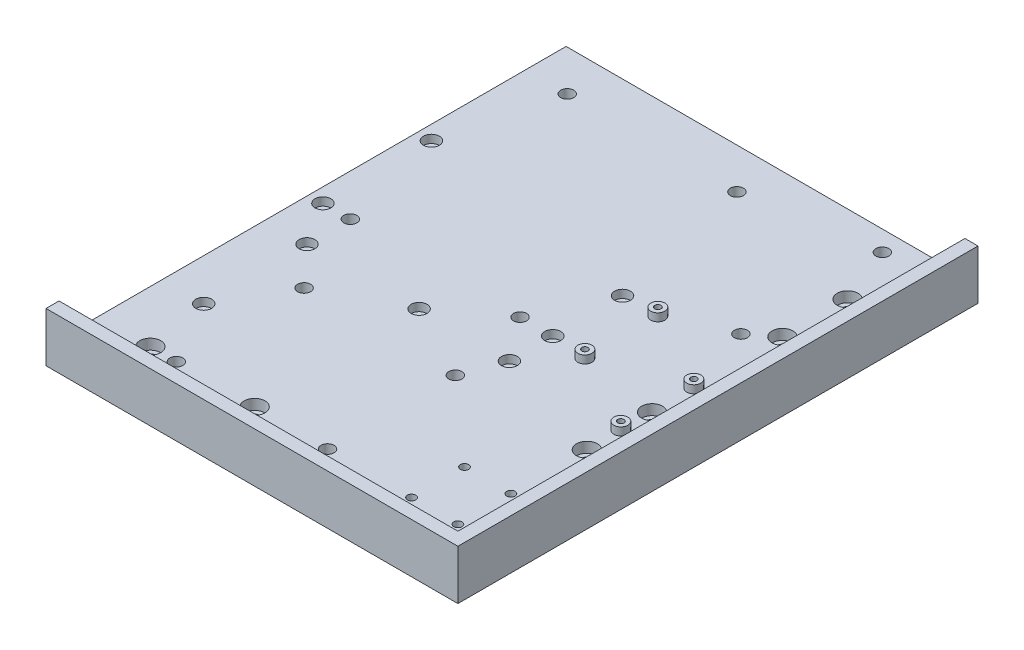
from build123d import *

# Parameters (mm, degrees)
SKETCH1_W                      = 158
SKETCH1_H                      = 199.5
BOSS_EXTRUDE1_DEPTH            = 6.35
BOSS_EXTRUDE2_DEPTH            = 12.7
CBORE_FOR_M4_SHCS1_D           = 4.5
CBORE_FOR_M4_SHCS1_DEPTH       = 6.35
CBORE_FOR_M4_SHCS1_CBORE_D     = 8
CBORE_FOR_M4_SHCS1_CBORE_DEPTH = 4
SKETCH8_R                      = 2.5
ESTOP_DEPTH                    = 7.35
SKETCH9_R                      = 2.5
NUCLEOANDPI_DEPTH              = 7.35
SKETCH10_R                     = 2.7
SKETCH10_R_2                   = 1.2
BUCKS_EXTRUDE_DEPTH            = 3
SKETCH11_R                     = 1.6
BUCKS_CUT_DEPTH                = 6.35
BUCK_2_COUNT                   = 2
BUCK_2_PITCH                   = 28
SKETCH12_R                     = 2.5
PI_2_DEPTH                     = 7.35
SKETCH13_R                     = 1.6
IMU_DEPTH                      = 7.35
SKETCH15_R                     = 3.05
MAGNETS_DEPTH                  = 3.1


with BuildPart() as part:
    # Sketch1 → Boss-Extrude1 (new body)
    with BuildSketch(Plane(origin=(0, 0, 0), x_dir=(1, 0, 0), z_dir=(0, 1, 0))):
        with Locations((79, -99.75)):
            Rectangle(SKETCH1_W, SKETCH1_H)
    extrude(amount=BOSS_EXTRUDE1_DEPTH)

    # Sketch3 → Boss-Extrude2 (add)
    with BuildSketch(Plane(origin=(0, 6.35, 0), x_dir=(1, 0, 0), z_dir=(0, 1, 0))):
        Polygon((158, -199.5), (158, 0), (153, 0), (153, -194.5), (0, -194.5), (0, -199.5), align=None)
    extrude(amount=BOSS_EXTRUDE2_DEPTH)

    # CBORE for M4 SHCS1
    with Locations(Plane(origin=(0, 6.35, 0), x_dir=(1, 0, 0), z_dir=(0, 1, 0))):
        with Locations((138, -55), (20, -179.5), (60, -179.5), (138, -130), (138, -105), (138, -30)):
            CounterBoreHole(CBORE_FOR_M4_SHCS1_D / 2, CBORE_FOR_M4_SHCS1_CBORE_D / 2, CBORE_FOR_M4_SHCS1_CBORE_DEPTH, depth=CBORE_FOR_M4_SHCS1_DEPTH)

    # Sketch8 → eStop (cut, through all)
    with BuildSketch(Plane(origin=(0, 6.35, 0), x_dir=(1, 0, 0), z_dir=(0, 1, 0))):
        with Locations((129.05, -62)):
            Circle(SKETCH8_R)
        with Locations((129.05, -7.75)):
            Circle(SKETCH8_R)
    extrude(amount=-ESTOP_DEPTH, mode=Mode.SUBTRACT)

    # Sketch9 → NucleoAndPi (cut, through all)
    with BuildSketch(Plane(origin=(0, 6.35, 0), x_dir=(1, 0, 0), z_dir=(0, 1, 0))):
        with Locations((16, -15.57)):
            Circle(SKETCH9_R)
        with Locations((81.1, -15.57)):
            Circle(SKETCH9_R)
        with Locations((81.1, -98.77)):
            Circle(SKETCH9_R)
        with Locations((16, -98.77)):
            Circle(SKETCH9_R)
    extrude(amount=-NUCLEOANDPI_DEPTH, mode=Mode.SUBTRACT)

    # Sketch10 → Bucks - Extrude (add)
    with BuildSketch(Plane(origin=(0, 6.35, 0), x_dir=(1, 0, 0), z_dir=(0, 1, 0))):
        with Locations((138, -89)):
            Circle(SKETCH10_R)
        with Locations((138, -89)):
            Circle(SKETCH10_R_2, mode=Mode.SUBTRACT)
        with Locations((107.2, -72)):
            Circle(SKETCH10_R)
        with Locations((107.2, -72)):
            Circle(SKETCH10_R_2, mode=Mode.SUBTRACT)
    bucks_extrude = extrude(amount=BUCKS_EXTRUDE_DEPTH)

    # Sketch11 → Bucks - Cut (cut)
    with BuildSketch(Plane(origin=(0, 6.35, 0), x_dir=(1, 0, 0), z_dir=(0, 1, 0))):
        with Locations((138, -89)):
            Circle(SKETCH11_R)
        with Locations((107.2, -72)):
            Circle(SKETCH11_R)
    bucks_cut = extrude(amount=-BUCKS_CUT_DEPTH, mode=Mode.SUBTRACT)

    # Buck 2: Bucks - Extrude, Bucks - Cut ×2
    with Locations(*[(0, 0, i * BUCK_2_PITCH) for i in range(1, BUCK_2_COUNT)]):
        add(bucks_extrude)
        add(bucks_cut, mode=Mode.SUBTRACT)

    # Sketch12 → Pi 2 (cut, through all)
    with BuildSketch(Plane(origin=(0, 6.35, 0), x_dir=(1, 0, 0), z_dir=(0, 1, 0))):
        with Locations((30, -130.5)):
            Circle(SKETCH12_R)
        with Locations((88, -130.5)):
            Circle(SKETCH12_R)
        with Locations((88, -179.5)):
            Circle(SKETCH12_R)
        with Locations((30, -179.5)):
            Circle(SKETCH12_R)
    extrude(amount=-PI_2_DEPTH, mode=Mode.SUBTRACT)

    # Sketch13 → IMU (cut, through all)
    with BuildSketch(Plane(origin=(0, 6.35, 0), x_dir=(1, 0, 0), z_dir=(0, 1, 0))):
        with Locations((120.22, -159.18)):
            Circle(SKETCH13_R)
        with Locations((120.22, -179.5)):
            Circle(SKETCH13_R)
        with Locations((138, -159.18)):
            Circle(SKETCH13_R)
        with Locations((138, -179.5)):
            Circle(SKETCH13_R)
    extrude(amount=-IMU_DEPTH, mode=Mode.SUBTRACT)

    # Sketch15 → MAGNETS (cut)
    with BuildSketch(Plane(origin=(0, 6.35, 0), x_dir=(1, 0, 0), z_dir=(0, 1, 0))):
        with Locations((5.5, -57.17)):
            Circle(SKETCH15_R)
        with Locations((5.5, -98.77)):
            Circle(SKETCH15_R)
        with Locations((16, -115.385)):
            Circle(SKETCH15_R)
        with Locations((59, -115.385)):
            Circle(SKETCH15_R)
        with Locations((93.65, -98.77)):
            Circle(SKETCH15_R)
        with Locations((93.65, -115.385)):
            Circle(SKETCH15_R)
        with Locations((93.65, -72)):
            Circle(SKETCH15_R)
        with Locations((16, -155)):
            Circle(SKETCH15_R)
    extrude(amount=-MAGNETS_DEPTH, mode=Mode.SUBTRACT)


solid = part.part
